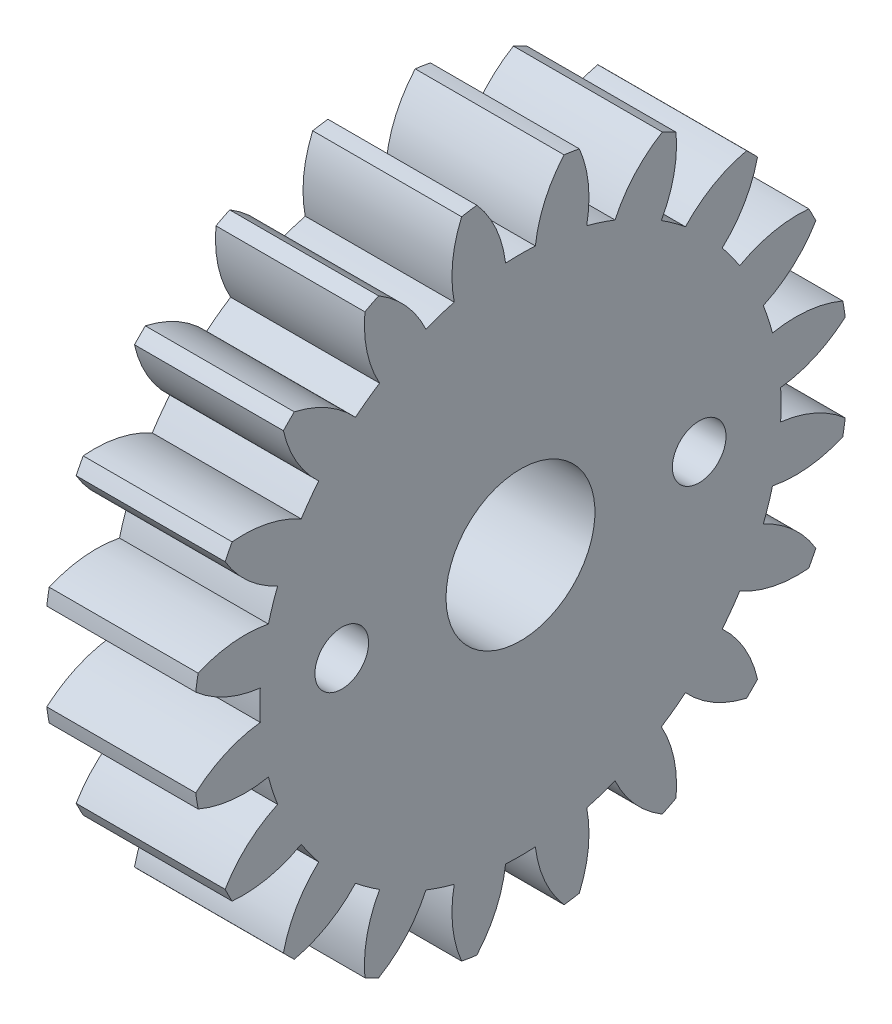
from build123d import *

# Parameters (mm, degrees)
BASPROSKE_W        = 5
BASPROSKE_H        = 11
TOOTHCUT_DEPTH     = 17.340134638
TEETHCUTS_COUNT    = 20
TEETHCUTS_ANGLE    = 342
BORSKE_R           = 2.5
BORE_DEPTH         = 50.0000508
SKETCH1_R          = 0.9
CUT_EXTRUDE1_DEPTH = 10


with BuildPart() as part:
    # BasProSke → Base-Revolve (revolve)
    with BuildSketch(Plane(origin=(0, 0, 0), x_dir=(1, 0, 0), z_dir=(0, 1, 0)), mode=Mode.PRIVATE) as base_revolve_sk:
        with Locations((2.5, 5.5)):
            Rectangle(BASPROSKE_W, BASPROSKE_H)
    revolve(base_revolve_sk.sketch.rotate(Axis((-10, 0, 0), (1, 0, 0)), 180), axis=Axis((-10, 0, 0), (1, 0, 0)))

    # TooCutSke → ToothCut (cut, through all)
    with BuildSketch(Plane(origin=(0, 0, 0), x_dir=(0, 0, -1), z_dir=(1, 0, 0))):
        with BuildLine():
            ThreePointArc((0.499924007, 8.734705318), (0, 8.749), (-0.499924007, 8.734705318))
            ThreePointArc((-0.499924007, 8.734705318), (-0.824302243, 9.905497836), (-1.485192705, 10.924909509))
            ThreePointArc((-1.485192705, 10.924909509), (0, 11.0254), (1.485192705, 10.924909509))
            ThreePointArc((1.485192705, 10.924909509), (0.824302243, 9.905497836), (0.499924007, 8.734705318))
        make_face()
    toothcut = extrude(amount=TOOTHCUT_DEPTH, mode=Mode.SUBTRACT)

    # TeethCuts: ToothCut ×20 about axis
    teethcuts_axis = Axis((-10, 0, 0), (1, 0, 0))
    for i in range(1, TEETHCUTS_COUNT):
        add(toothcut.rotate(teethcuts_axis, i * TEETHCUTS_ANGLE / (TEETHCUTS_COUNT - 1)), mode=Mode.SUBTRACT)

    # BorSke → Bore (cut, symmetric)
    with BuildSketch(Plane(origin=(0, 0, 0), x_dir=(0, 0, -1), z_dir=(1, 0, 0))):
        with Locations(Location((0, 0, 0), (0, 0, 180))):
            Circle(BORSKE_R)
    extrude(amount=BORE_DEPTH, both=True, mode=Mode.SUBTRACT)

    # Sketch1 → Cut-Extrude1 (cut)
    with BuildSketch(Plane(origin=(5, 0, 0), x_dir=(0, 0, -1), z_dir=(1, 0, 0))):
        with Locations((6, 0)):
            Circle(SKETCH1_R)
        with Locations((-6, 0)):
            Circle(SKETCH1_R)
    extrude(amount=-CUT_EXTRUDE1_DEPTH, mode=Mode.SUBTRACT)


solid = part.part
